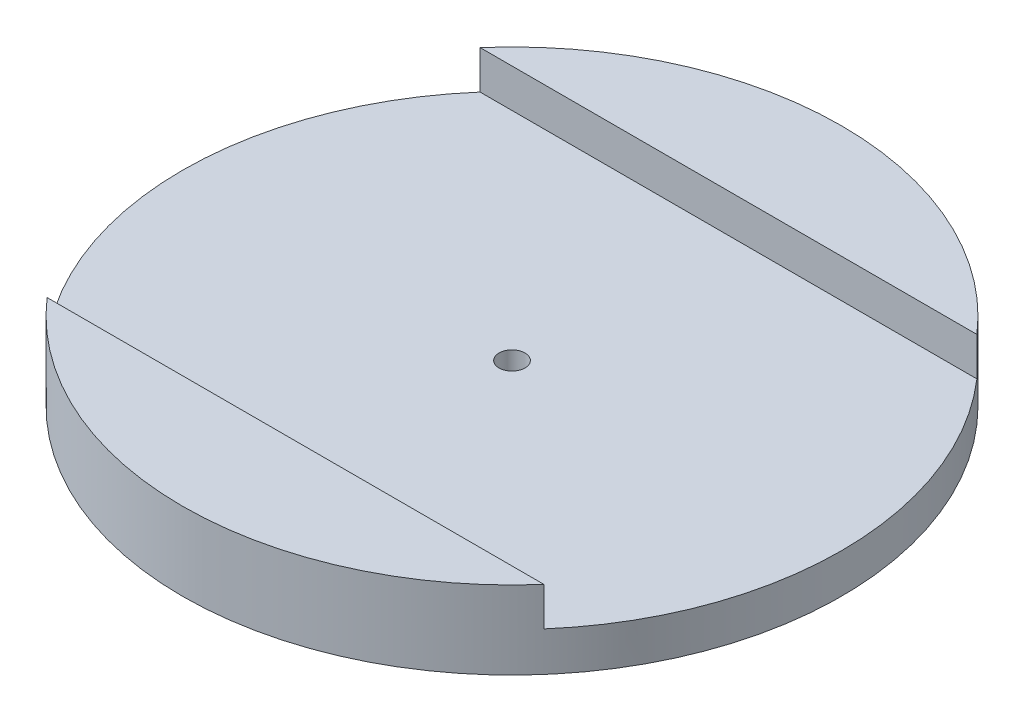
from build123d import *

# Parameters (mm, degrees)
SKETCH1_R           = 76
BOSS_EXTRUDE1_DEPTH = 18
CUT_EXTRUDE4_DEPTH  = 8.89
SKETCH5_R           = 3
CUT_EXTRUDE5_DEPTH  = 20


with BuildPart() as part:
    # Sketch1 → Boss-Extrude1 (new body)
    with BuildSketch(Plane(origin=(0, 0, 0), x_dir=(1, 0, 0), z_dir=(0, 1, 0))):
        Circle(SKETCH1_R)
    extrude(amount=BOSS_EXTRUDE1_DEPTH)

    # Sketch2 → Cut-Extrude4 (cut)
    with BuildSketch(Plane(origin=(0, 18, 0), x_dir=(1, 0, 0), z_dir=(0, 1, 0))):
        with BuildLine():
            Line((-58.007955522, 49.931796385), (58.007955522, 49.931796385))
            ThreePointArc((58.007955522, 49.931796385), (107.939751907, 0), (58.007955522, -49.931796385))
            Line((58.007955522, -49.931796385), (-58.007955522, -49.931796385))
            ThreePointArc((-58.007955522, -49.931796385), (-107.939751907, 0), (-58.007955522, 49.931796385))
        make_face()
    extrude(amount=-CUT_EXTRUDE4_DEPTH, mode=Mode.SUBTRACT)

    # Sketch5 → Cut-Extrude5 (cut)
    with BuildSketch(Plane(origin=(0, 9.11, 0), x_dir=(1, 0, 0), z_dir=(0, 1, 0))):
        Circle(SKETCH5_R)
    extrude(amount=-CUT_EXTRUDE5_DEPTH, mode=Mode.SUBTRACT)


solid = part.part
